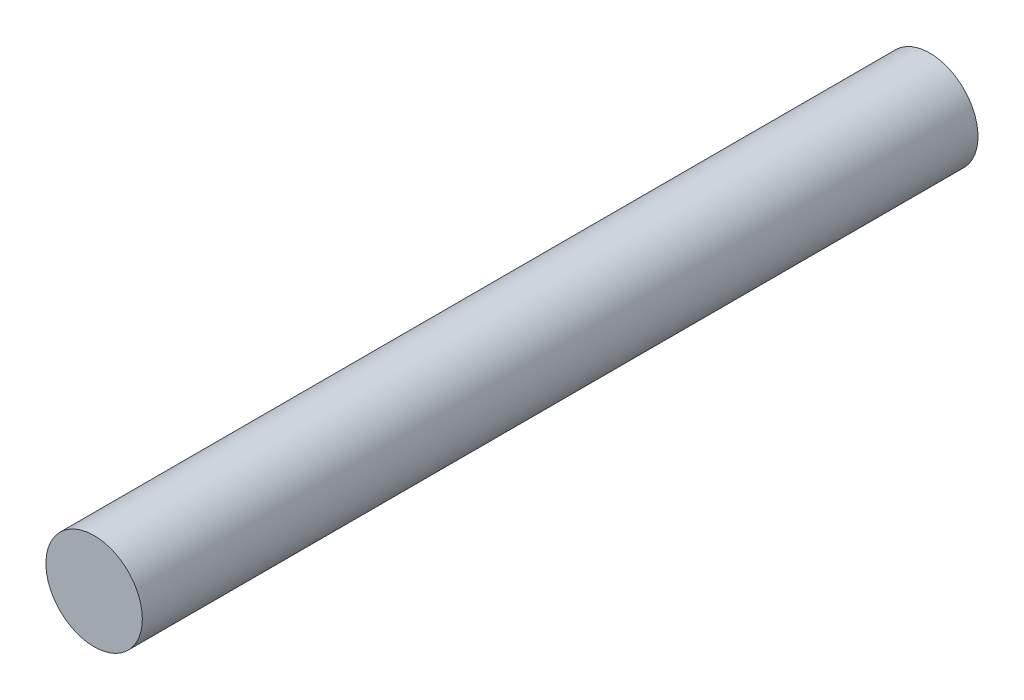
from build123d import *

# Parameters (mm, degrees)
SKETCH1_R           = 3
BOSS_EXTRUDE1_DEPTH = 52


with BuildPart() as part:
    # Sketch1 → Boss-Extrude1 (new body)
    with BuildSketch(Plane.XY):
        Circle(SKETCH1_R)
    extrude(amount=BOSS_EXTRUDE1_DEPTH)


solid = part.part
